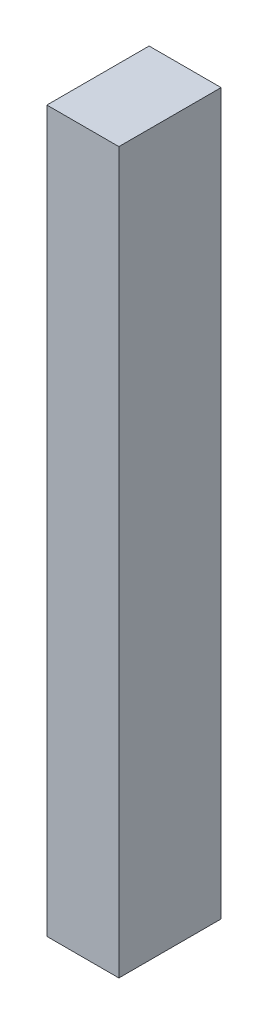
from build123d import *

# Parameters (mm, degrees)
SKETCH1_W           = 20
SKETCH1_H           = 200
BOSS_EXTRUDE1_DEPTH = 28.4


with BuildPart() as part:
    # Sketch1 → Boss-Extrude1 (new body)
    with BuildSketch(Plane.XY):
        with Locations((10, 100)):
            Rectangle(SKETCH1_W, SKETCH1_H)
    extrude(amount=BOSS_EXTRUDE1_DEPTH)


solid = part.part
